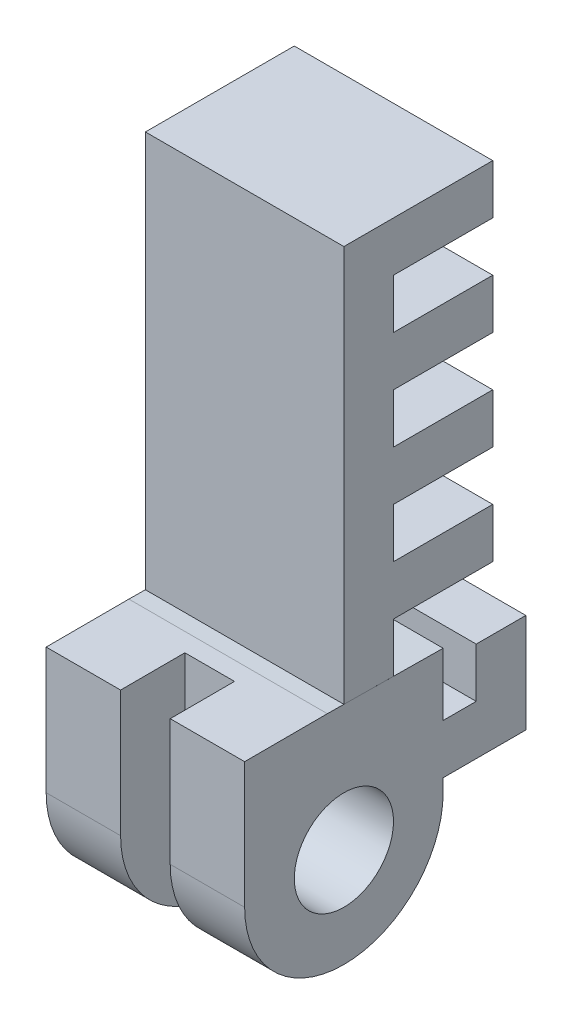
from build123d import *

# Parameters (mm, degrees)
SKETCH4_R           = 3
BOSS_EXTRUDE2_DEPTH = 12
BOSS_EXTRUDE3_DEPTH = 12
CUT_EXTRUDE1_START  = -4.5
CUT_EXTRUDE1_DEPTH  = 3
BOSS_EXTRUDE4_DEPTH = 12


with BuildPart() as part:
    # Sketch4 → Boss-Extrude2 (new body)
    with BuildSketch(Plane(origin=(0, 0, 0), x_dir=(0, 0, -1), z_dir=(1, 0, 0))):
        with BuildLine():
            Line((114.889686184, -68.26593045), (117.889565828, -68.297153403))
            Line((117.889565828, -68.297153403), (120.925943631, -68.328756232))
            Line((120.925943631, -68.328756232), (121.889620656, -68.338786248))
            Line((121.889620656, -68.338786248), (121.889620656, -75.903550783))
            ThreePointArc((121.889620656, -75.903550783), (115.889620656, -81.903550783), (109.889620656, -75.903550783))
            Line((109.889620656, -75.903550783), (109.889620656, -68.277498728))
            Line((109.889620656, -68.277498728), (114.889686184, -68.26593045))
        make_face()
        with Locations((115.889620656, -75.903550783)):
            Circle(SKETCH4_R, mode=Mode.SUBTRACT)
    extrude(amount=-BOSS_EXTRUDE2_DEPTH)

    # Sketch3 → Cut-Extrude1 (cut)
    with BuildSketch(Plane(origin=(0, 0, 0), x_dir=(0, 0, -1), z_dir=(1, 0, 0)).offset(CUT_EXTRUDE1_START)):
        Polygon((108.275790375, -67.274508057), (108.275790375, -83.274508057), (119.775790375, -83.274508057), (119.775790375, -77.274508057), (113.775790375, -77.274508057), (113.775790375, -67.274508057), align=None)
    extrude(amount=-CUT_EXTRUDE1_DEPTH, mode=Mode.SUBTRACT)

    # Sketch7 → Boss-Extrude4 (add)
    with BuildSketch(Plane(origin=(0, 0, 0), x_dir=(0, 0, -1), z_dir=(1, 0, 0))):
        Polygon((121.889620656, -72.121168516), (123.889620656, -72.121168516), (123.889620656, -69.121168516), (126.889620656, -69.121168516), (126.889620656, -75.121168516), (121.889620656, -75.121168516), align=None)
    extrude(amount=-BOSS_EXTRUDE4_DEPTH)


with BuildPart() as body_2:
    # Sketch5 → Boss-Extrude3 (new body)
    with BuildSketch(Plane(origin=(0, 0, 0), x_dir=(0, 0, -1), z_dir=(1, 0, 0))):
        Polygon((115.889620656, -44.306404862), (115.889620656, -68.276337837), (118.889522363, -68.306404862), (118.889522363, -65.306404862), (124.889522363, -65.306404862), (124.889522363, -62.306404862), (118.889522363, -62.306404862), (118.889522363, -59.306404862), (124.889522363, -59.306404862), (124.889522363, -56.306404862), (118.889522363, -56.306404862), (118.889522363, -53.306404862), (124.889522363, -53.306404862), (124.889522363, -50.306404862), (118.889522363, -50.306404862), (118.889522363, -47.306404862), (124.889522363, -47.306404862), (124.889522363, -44.306404862), align=None)
    extrude(amount=-BOSS_EXTRUDE3_DEPTH)


solid = Compound([part.part, body_2.part])
